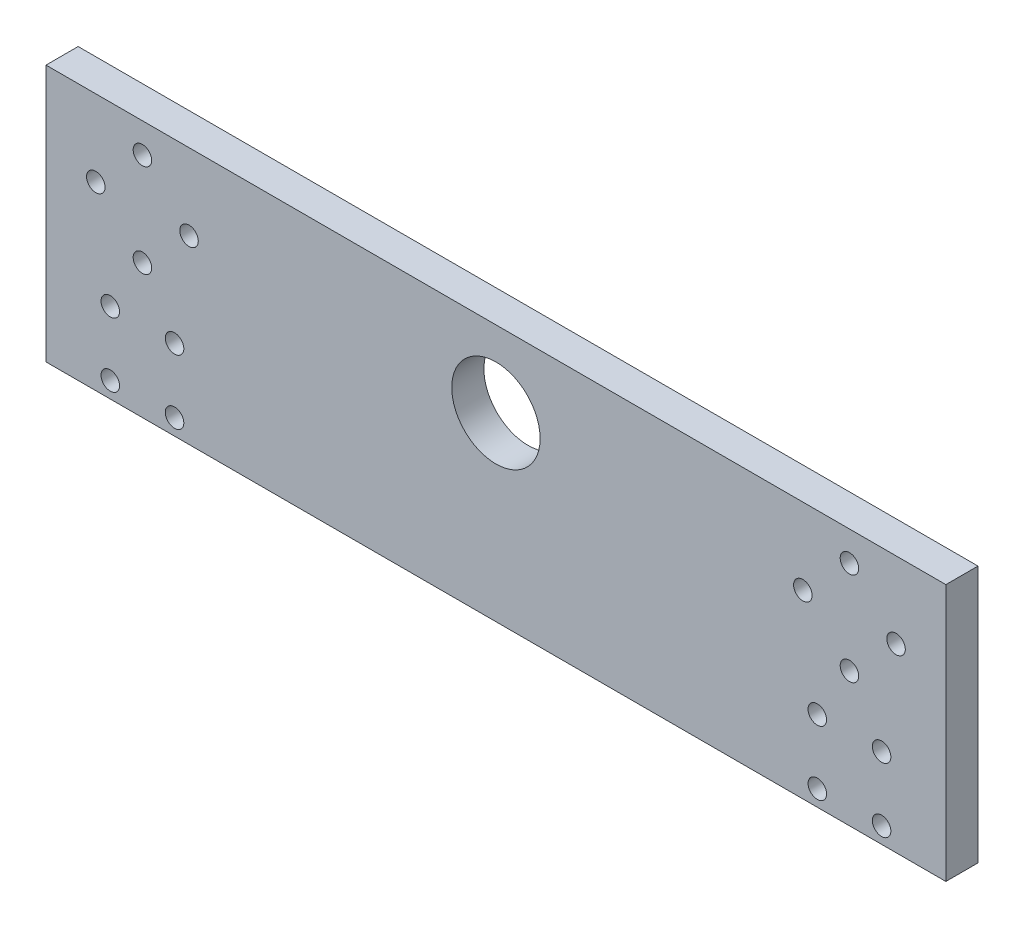
from build123d import *

# Parameters (mm, degrees)
SKETCH1_W           = 177.8
SKETCH1_H           = 50.8
SKETCH1_R           = 8.73125
SKETCH1_R_2         = 1.8288
BOSS_EXTRUDE1_DEPTH = 6.35


with BuildPart() as part:
    # Sketch1 → Boss-Extrude1 (new body)
    with BuildSketch(Plane.XY):
        with Locations((0, -10.31875)):
            Rectangle(SKETCH1_W, SKETCH1_H)
        Circle(SKETCH1_R, mode=Mode.SUBTRACT)
        with Locations((-79.0575, 0)):
            Circle(SKETCH1_R_2, mode=Mode.SUBTRACT)
        with Locations((-60.6425, 0)):
            Circle(SKETCH1_R_2, mode=Mode.SUBTRACT)
        with Locations((60.6425, 0)):
            Circle(SKETCH1_R_2, mode=Mode.SUBTRACT)
        with Locations((79.0575, 0)):
            Circle(SKETCH1_R_2, mode=Mode.SUBTRACT)
        with Locations((69.85, 9.2075)):
            Circle(SKETCH1_R_2, mode=Mode.SUBTRACT)
        with Locations((69.85, -9.2075)):
            Circle(SKETCH1_R_2, mode=Mode.SUBTRACT)
        with Locations((-69.85, 9.2075)):
            Circle(SKETCH1_R_2, mode=Mode.SUBTRACT)
        with Locations((-69.85, -9.2075)):
            Circle(SKETCH1_R_2, mode=Mode.SUBTRACT)
        with Locations((-76.2, -19.84375)):
            Circle(SKETCH1_R_2, mode=Mode.SUBTRACT)
        with Locations((-63.5, -19.84375)):
            Circle(SKETCH1_R_2, mode=Mode.SUBTRACT)
        with Locations((-63.5, -32.54375)):
            Circle(SKETCH1_R_2, mode=Mode.SUBTRACT)
        with Locations((-76.2, -32.54375)):
            Circle(SKETCH1_R_2, mode=Mode.SUBTRACT)
        with Locations((63.5, -19.84375)):
            Circle(SKETCH1_R_2, mode=Mode.SUBTRACT)
        with Locations((76.2, -19.84375)):
            Circle(SKETCH1_R_2, mode=Mode.SUBTRACT)
        with Locations((76.2, -32.54375)):
            Circle(SKETCH1_R_2, mode=Mode.SUBTRACT)
        with Locations((63.5, -32.54375)):
            Circle(SKETCH1_R_2, mode=Mode.SUBTRACT)
    extrude(amount=BOSS_EXTRUDE1_DEPTH)


solid = part.part
